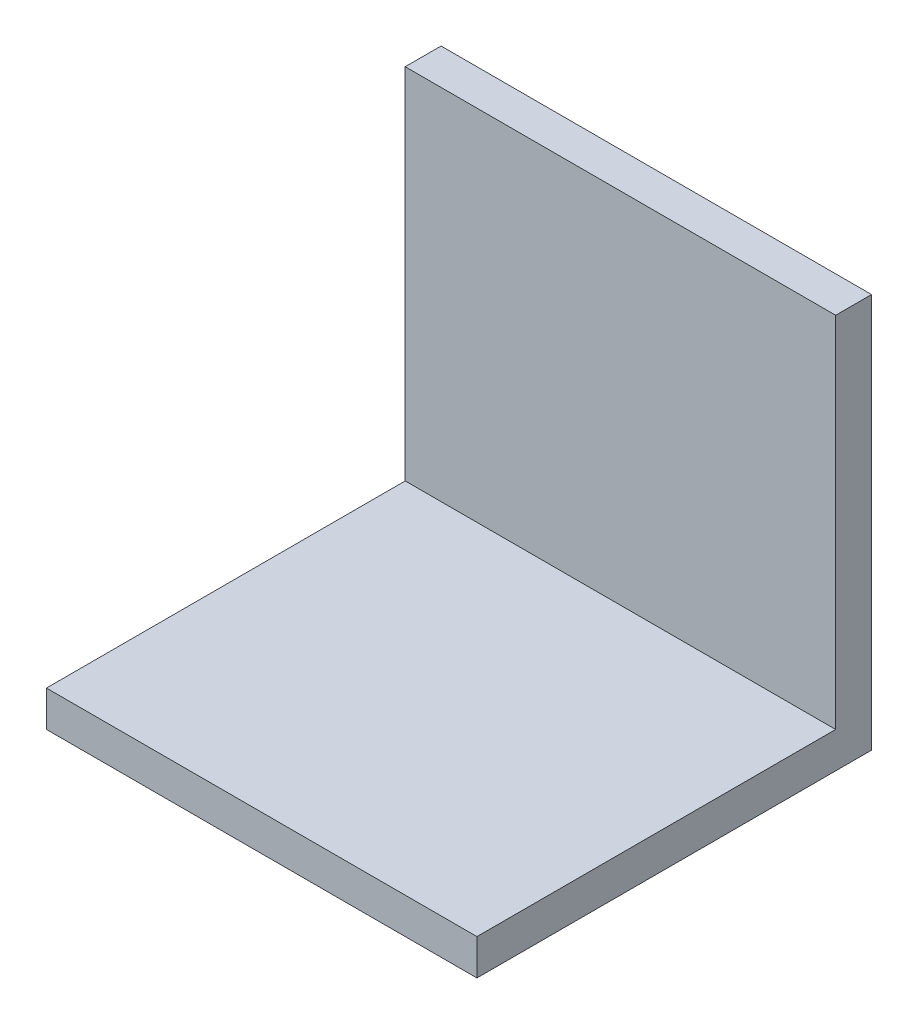
from build123d import *

# Parameters (mm, degrees)
SKETCH1_W           = 36
SKETCH1_H           = 33
BOSS_EXTRUDE1_DEPTH = 3
SKETCH2_W           = 36
SKETCH2_H           = 3
BOSS_EXTRUDE2_DEPTH = 30


with BuildPart() as part:
    # Sketch1 → Boss-Extrude1 (new body)
    with BuildSketch(Plane.XY):
        Rectangle(SKETCH1_W, SKETCH1_H)
    extrude(amount=BOSS_EXTRUDE1_DEPTH)

    # Sketch2 → Boss-Extrude2 (add)
    with BuildSketch(Plane.XY.offset(3)):
        with Locations((0, -15)):
            Rectangle(SKETCH2_W, SKETCH2_H)
    extrude(amount=BOSS_EXTRUDE2_DEPTH)


solid = part.part
